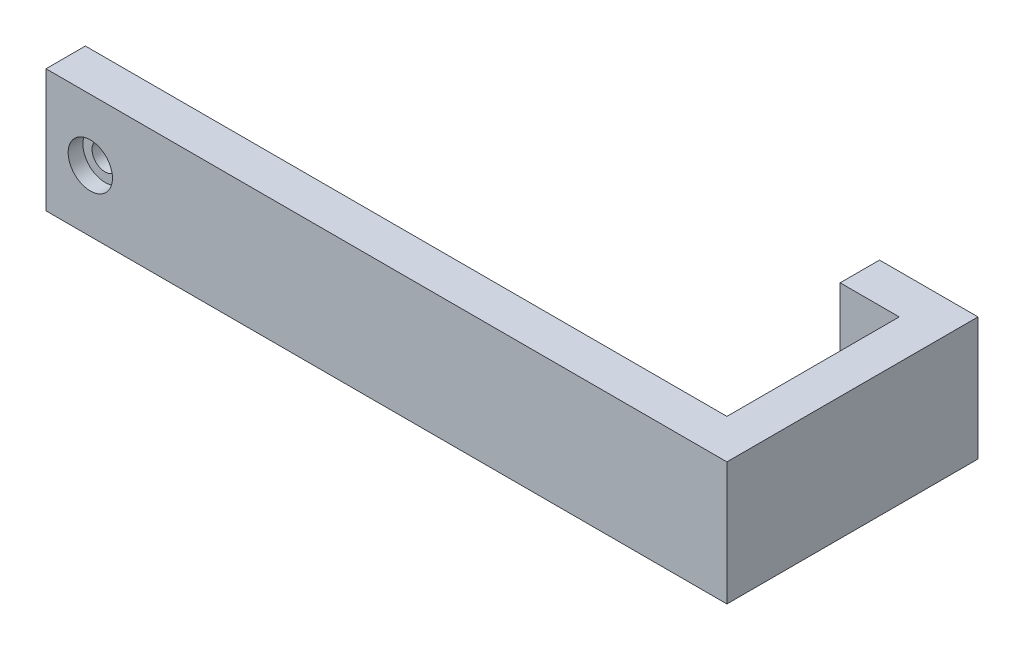
from build123d import *

# Parameters (mm, degrees)
SKETCH_1_R          = 2.65
EXTRUDE_1_DEPTH     = 8
SKETCH_7_W          = 8
SKETCH_7_H          = 25
EXTRUDE_2_DEPTH     = 43
SKETCH_8_W          = 8
SKETCH_8_H          = 25
EXTRUDE_3_DEPTH     = 12
SKETCH_9_R          = 4.5
CUT_EXTRUDE_1_DEPTH = 3


with BuildPart() as part:
    # 草图1 → 凸台-拉伸1 (new body)
    with BuildSketch(Plane.XY):
        Polygon((-8, 12.5), (129.3, 12.5), (129.3, -12.5), (-8, -12.5), (-9, -12.5), (-9, 12.5), align=None)
        Circle(SKETCH_1_R, mode=Mode.SUBTRACT)
    extrude(amount=EXTRUDE_1_DEPTH)

    # 草图7 → 凸台-拉伸2 (add)
    with BuildSketch(Plane(origin=(0, 0, 0), x_dir=(-1, 0, 0), z_dir=(0, 0, -1))):
        with Locations((-125.3, 0)):
            Rectangle(SKETCH_7_W, SKETCH_7_H)
    extrude(amount=EXTRUDE_2_DEPTH)

    # 草图8 → 凸台-拉伸3 (add)
    with BuildSketch(Plane.ZY.offset(-121.3)):
        with Locations((-39, 0)):
            Rectangle(SKETCH_8_W, SKETCH_8_H)
    extrude(amount=EXTRUDE_3_DEPTH)

    # 草图9 → 切除-拉伸1 (cut)
    with BuildSketch(Plane.XY.offset(8)):
        Circle(SKETCH_9_R)
    extrude(amount=-CUT_EXTRUDE_1_DEPTH, mode=Mode.SUBTRACT)


solid = part.part
